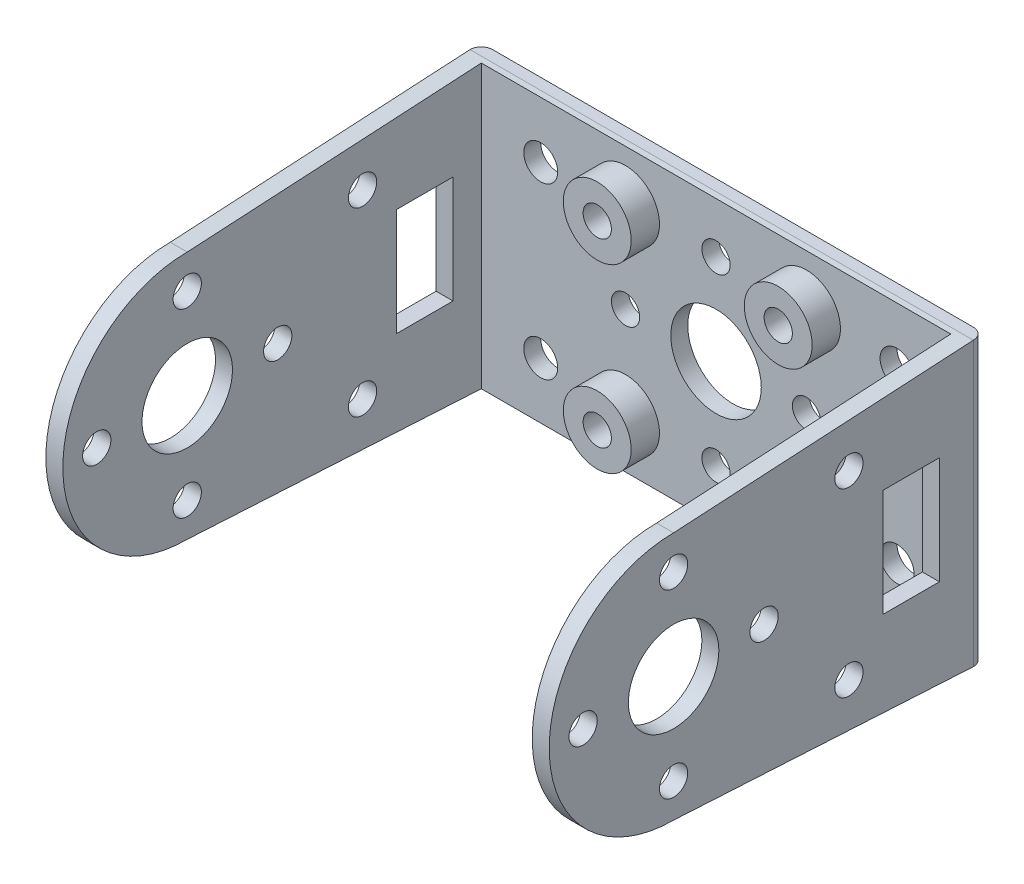
from build123d import *

# Parameters (mm, degrees)
SKETCH1_W           = 44.5
SKETCH1_H           = 25
BOSS_EXTRUDE1_DEPTH = 38.5
SKETCH2_W           = 41.5
SKETCH2_H           = 25
CUT_EXTRUDE1_DEPTH  = 37
FILLET1_R           = 1
SKETCH3_R           = 3
BOSS_EXTRUDE2_DEPTH = 2.5
SKETCH4_R           = 1.5
CUT_EXTRUDE2_DEPTH  = 1.5
SKETCH5_R           = 1.25
SKETCH5_R_2         = 4
CUT_EXTRUDE5_DEPTH  = 4
SKETCH6_W           = 5
SKETCH6_H           = 9.5
CUT_EXTRUDE6_DEPTH  = 44.5
SKETCH7_R           = 4
CUT_EXTRUDE7_DEPTH  = 44.5
SKETCH8_R           = 1.25
CUT_EXTRUDE8_DEPTH  = 44.5


with BuildPart() as part:
    # Sketch1 → Boss-Extrude1 (new body)
    with BuildSketch(Plane.XY):
        with Locations((22.25, 12.5)):
            Rectangle(SKETCH1_W, SKETCH1_H)
    extrude(amount=BOSS_EXTRUDE1_DEPTH)

    # Sketch2 → Cut-Extrude1 (cut)
    with BuildSketch(Plane.XY.offset(38.5)):
        with Locations((22.25, 12.5)):
            Rectangle(SKETCH2_W, SKETCH2_H)
    extrude(amount=-CUT_EXTRUDE1_DEPTH, mode=Mode.SUBTRACT)

    # Fillet1
    fillet1_edges = [part.edges().sort_by_distance(p)[0] for p in [
        (44.5, 12.5, 0),
        (0, 12.5, 0),
    ]]
    fillet(fillet1_edges, radius=FILLET1_R)

    # Sketch3 → Boss-Extrude2 (add)
    with BuildSketch(Plane.XY.offset(1.5)):
        with Locations((14.25, 4.5)):
            Circle(SKETCH3_R)
        with Locations((30.25, 4.5)):
            Circle(SKETCH3_R)
        with Locations((30.25, 20.5)):
            Circle(SKETCH3_R)
        with Locations((14.25, 20.5)):
            Circle(SKETCH3_R)
    extrude(amount=BOSS_EXTRUDE2_DEPTH)

    # Sketch4 → Cut-Extrude2 (cut)
    with BuildSketch(Plane.XY.offset(1.5)):
        with Locations((6.75, 20)):
            Circle(SKETCH4_R)
        with Locations((38.25, 20)):
            Circle(SKETCH4_R)
        with Locations((38.25, 5)):
            Circle(SKETCH4_R)
        with Locations((6.75, 5)):
            Circle(SKETCH4_R)
    extrude(amount=-CUT_EXTRUDE2_DEPTH, mode=Mode.SUBTRACT)

    # Sketch5 → Cut-Extrude5 (cut)
    with BuildSketch(Plane.XY.offset(4)):
        with Locations((22.25, 20.5)):
            Circle(SKETCH5_R)
        with Locations((30.25, 20.5)):
            Circle(SKETCH5_R)
        with Locations((14.25, 20.5)):
            Circle(SKETCH5_R)
        with Locations((22.25, 12.5)):
            Circle(SKETCH5_R_2)
        with Locations((30.25, 12.5)):
            Circle(SKETCH5_R)
        with Locations((22.25, 4.5)):
            Circle(SKETCH5_R)
        with Locations((30.25, 4.5)):
            Circle(SKETCH5_R)
        with Locations((14.25, 12.5)):
            Circle(SKETCH5_R)
        with Locations((14.25, 4.5)):
            Circle(SKETCH5_R)
    extrude(amount=-CUT_EXTRUDE5_DEPTH, mode=Mode.SUBTRACT)

    # Sketch6 → Cut-Extrude6 (cut)
    with BuildSketch(Plane(origin=(44.5, 0, 0), x_dir=(0, 0, -1), z_dir=(1, 0, 0))):
        with Locations((-6.5, 12.75)):
            Rectangle(SKETCH6_W, SKETCH6_H)
    extrude(amount=-CUT_EXTRUDE6_DEPTH, mode=Mode.SUBTRACT)

    # Sketch7 → Cut-Extrude7 (cut)
    with BuildSketch(Plane(origin=(44.5, 0, 0), x_dir=(0, 0, -1), z_dir=(1, 0, 0))):
        with Locations((-27.5, 12.5)):
            Circle(SKETCH7_R)
        with BuildLine():
            ThreePointArc((-38.5, 12.5), (-35.278174593, 20.278174593), (-27.5, 23.5))
            Line((-27.5, 23.5), (-1, 25))
            Line((-1, 25), (-38.5, 25))
            Line((-38.5, 25), (-38.5, 12.5))
        make_face()
        with BuildLine():
            ThreePointArc((-27.5, 1.5), (-35.278174593, 4.721825407), (-38.5, 12.5))
            Line((-38.5, 12.5), (-38.5, 0))
            Line((-38.5, 0), (-1, 0))
            Line((-1, 0), (-27.5, 1.5))
        make_face()
    extrude(amount=-CUT_EXTRUDE7_DEPTH, mode=Mode.SUBTRACT)

    # Sketch8 → Cut-Extrude8 (cut)
    with BuildSketch(Plane(origin=(44.5, 0, 0), x_dir=(0, 0, -1), z_dir=(1, 0, 0))):
        with Locations((-19.5, 12.5)):
            Circle(SKETCH8_R)
        with Locations((-35.5, 12.5)):
            Circle(SKETCH8_R)
        with Locations((-27.5, 4.5)):
            Circle(SKETCH8_R)
        with Locations((-12, 4.5)):
            Circle(SKETCH8_R)
        with Locations((-12, 20.5)):
            Circle(SKETCH8_R)
        with Locations((-27.5, 20.5)):
            Circle(SKETCH8_R)
    extrude(amount=-CUT_EXTRUDE8_DEPTH, mode=Mode.SUBTRACT)


solid = part.part
